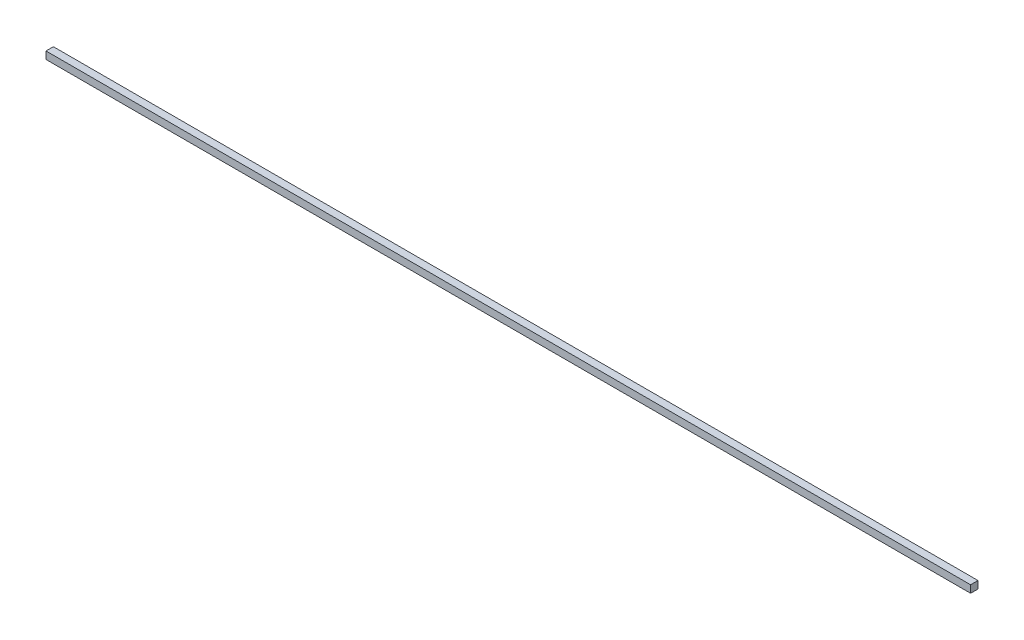
from build123d import *

# Parameters (mm, degrees)
SKETCH1_W           = 1250
SKETCH1_H           = 10
BOSS_EXTRUDE1_DEPTH = 10


with BuildPart() as part:
    # Sketch1 → Boss-Extrude1 (new body)
    with BuildSketch(Plane(origin=(0, 0, 0), x_dir=(1, 0, 0), z_dir=(0, 1, 0))):
        Rectangle(SKETCH1_W, SKETCH1_H)
    extrude(amount=BOSS_EXTRUDE1_DEPTH)


solid = part.part
